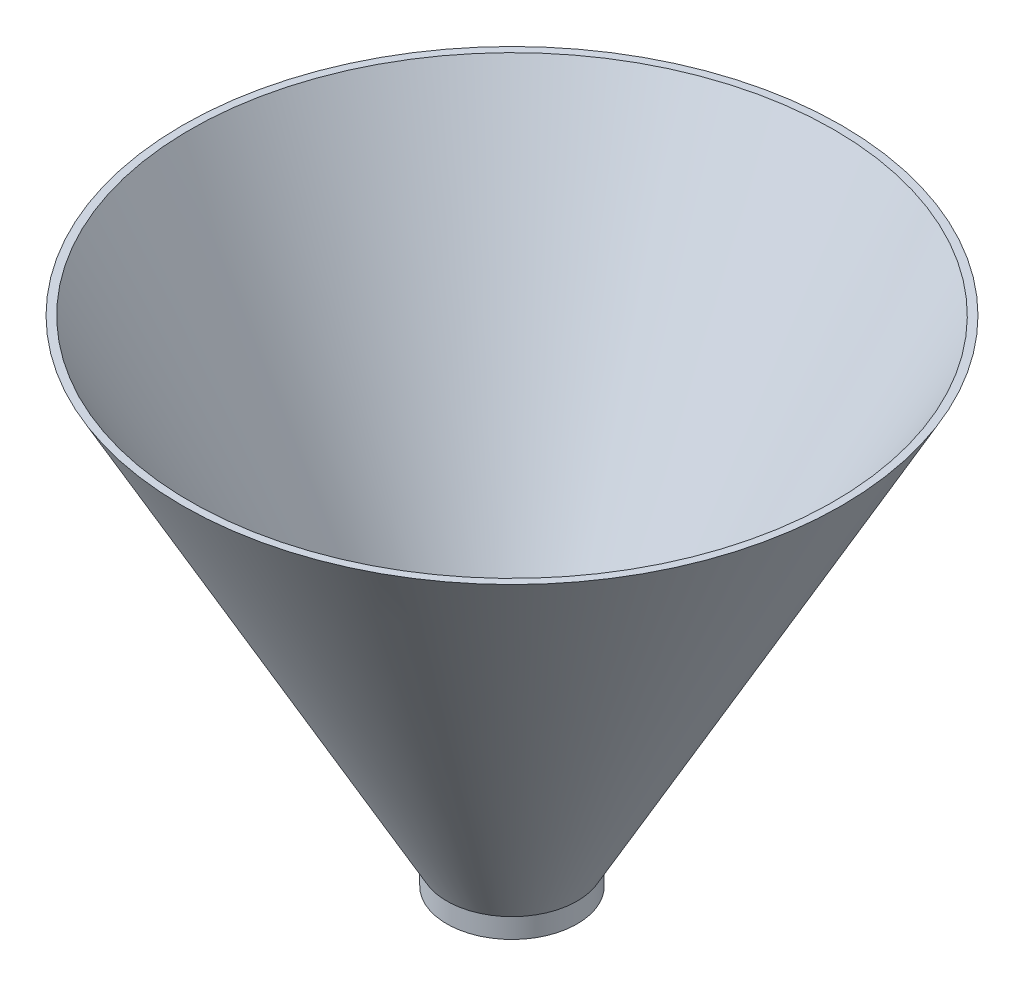
from build123d import *

# Parameters (mm, degrees)
SKETCH2_W               = 100
SKETCH2_H               = 0.486569872
CUT_EXTRUDE1_DEPTH      = 51
CUT_EXTRUDE1_DEPTH_BACK = 51


with BuildPart() as part:
    # Sketch1 → Revolve-Thin2 (revolve)
    with BuildSketch(Plane(origin=(0, 0, 0), x_dir=(0, 0, -1), z_dir=(1, 0, 0))):
        Polygon((9.9, 0), (9.9, 3), (50, 75), (49.126358335, 75.486569872), (8.9, 3.259692064), (8.9, 0), align=None)
    revolve(axis=Axis((0, 0, 0), (0, 1, 0)))

    # Sketch2 → Cut-Extrude1 (cut, two sides)
    with BuildSketch(Plane(origin=(0, 0, 0), x_dir=(0, 0, -1), z_dir=(1, 0, 0))) as cut_extrude1_sk:
        with Locations((0, 75.243284936)):
            Rectangle(SKETCH2_W, SKETCH2_H)
    extrude(amount=CUT_EXTRUDE1_DEPTH, mode=Mode.SUBTRACT)
    extrude(cut_extrude1_sk.sketch, amount=-CUT_EXTRUDE1_DEPTH_BACK, mode=Mode.SUBTRACT)


solid = part.part
